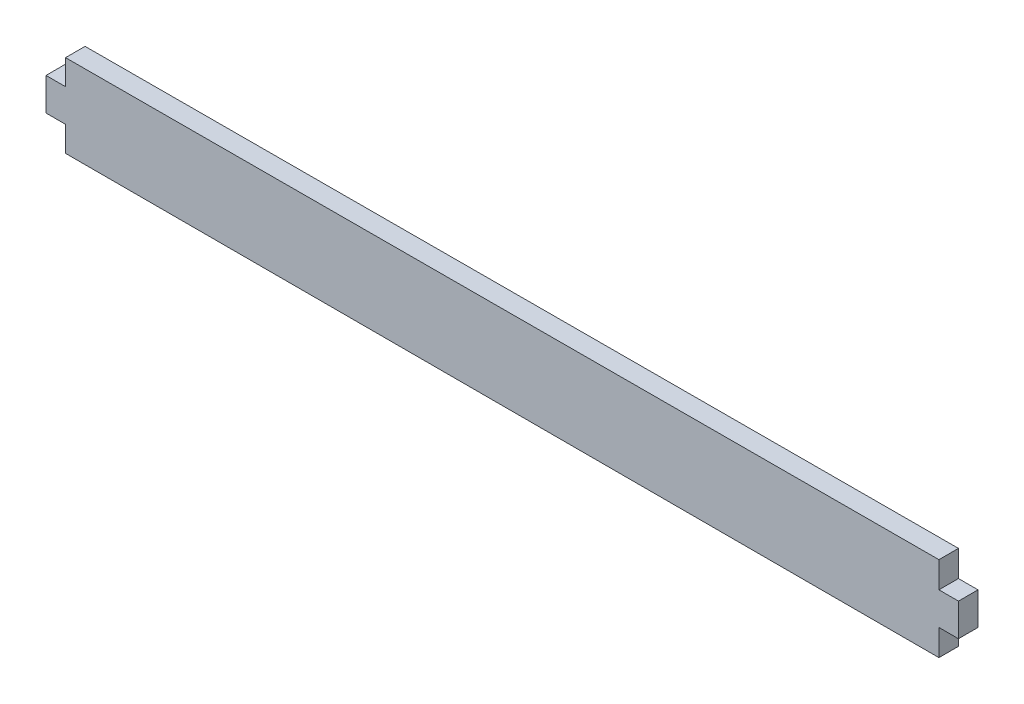
from build123d import *

# Parameters (mm, degrees)
SKETCH1_W      = 5.9944
SKETCH1_H      = 10
EXTRUDE1_DEPTH = 5.9944


with BuildPart() as part:
    # Sketch1 → Extrude1 (new body)
    with BuildSketch(Plane.XY):
        Polygon((-209.134206709, 4.793644232), (58.827458806, 4.793644232), (58.827458806, 30.831866903), (-209.134206709, 30.234993462), align=None)
        with Locations((-212.131406709, 17.514318847)):
            Rectangle(SKETCH1_W, SKETCH1_H)
        with Locations((61.824658806, 17.812755567)):
            Rectangle(SKETCH1_W, SKETCH1_H)
    extrude(amount=EXTRUDE1_DEPTH)


solid = part.part
